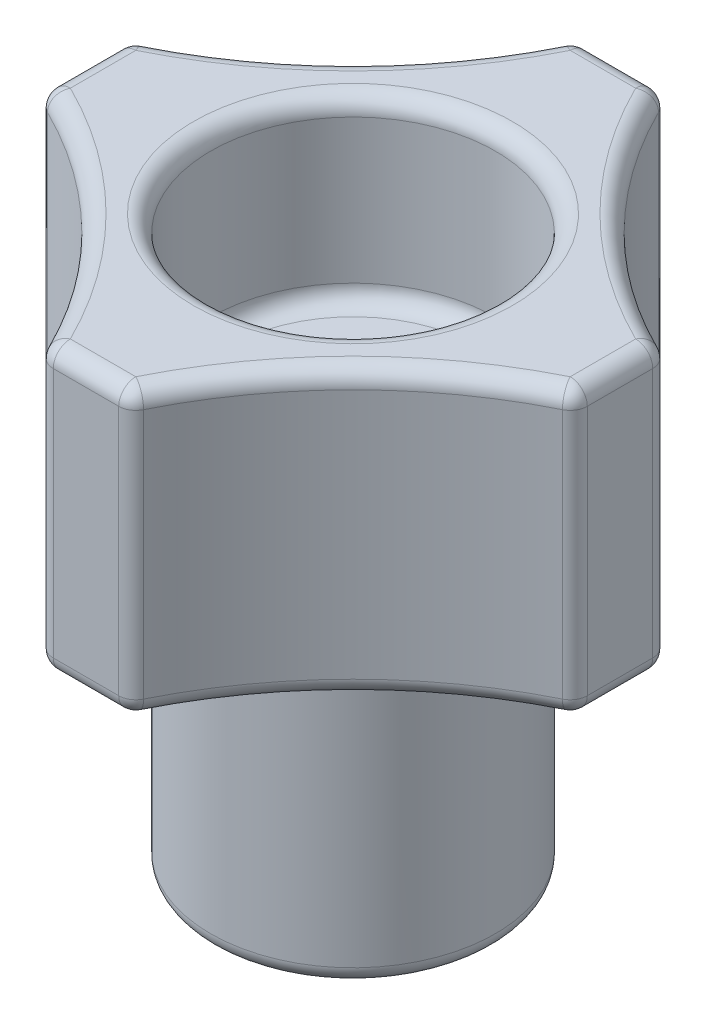
from build123d import *

# Parameters (mm, degrees)
SKETCH1_W           = 23.8125
SKETCH1_H           = 23.8125
BOSS_EXTRUDE1_DEPTH = 12.7
SKETCH3_R           = 20.6375
CUT_EXTRUDE1_DEPTH  = 22.090461781
CIRPATTERN1_COUNT   = 4
SKETCH4_R           = 6.35
BOSS_EXTRUDE2_DEPTH = 12.7
SKETCH5_R           = 3.175
CUT_EXTRUDE2_DEPTH  = 31.47421169
SKETCH6_R           = 6.35
CUT_EXTRUDE3_DEPTH  = 7.9375
FILLET1_R           = 0.762


with BuildPart() as part:
    # Sketch1 → Boss-Extrude1 (new body)
    with BuildSketch(Plane(origin=(0, 0, 0), x_dir=(1, 0, 0), z_dir=(0, 1, 0))):
        Rectangle(SKETCH1_W, SKETCH1_H)
    extrude(amount=BOSS_EXTRUDE1_DEPTH)

    # Sketch3 → Cut-Extrude1 (cut, through all)
    with BuildSketch(Plane(origin=(0, 12.7, 0), x_dir=(1, 0, 0), z_dir=(0, 1, 0))):
        with Locations((20.6375, 20.6375)):
            Circle(SKETCH3_R)
    cut_extrude1 = extrude(amount=-CUT_EXTRUDE1_DEPTH, mode=Mode.SUBTRACT)

    # CirPattern1: Cut-Extrude1 ×4 about axis
    cirpattern1_axis = Axis((0, 50, 0), (0, -1, 0))
    for i in range(1, CIRPATTERN1_COUNT):
        add(cut_extrude1.rotate(cirpattern1_axis, i * 360 / CIRPATTERN1_COUNT), mode=Mode.SUBTRACT)

    # Sketch4 → Boss-Extrude2 (add)
    with BuildSketch(Plane.XZ):
        Circle(SKETCH4_R)
    extrude(amount=BOSS_EXTRUDE2_DEPTH)

    # Sketch5 → Cut-Extrude2 (cut, through all)
    with BuildSketch(Plane(origin=(0, 12.7, 0), x_dir=(1, 0, 0), z_dir=(0, 1, 0))):
        Circle(SKETCH5_R)
    extrude(amount=-CUT_EXTRUDE2_DEPTH, mode=Mode.SUBTRACT)

    # Sketch6 → Cut-Extrude3 (cut)
    with BuildSketch(Plane(origin=(0, 12.7, 0), x_dir=(1, 0, 0), z_dir=(0, 1, 0))):
        Circle(SKETCH6_R)
    extrude(amount=-CUT_EXTRUDE3_DEPTH, mode=Mode.SUBTRACT)

    # Fillet1
    fillet1_edges = [part.edges().sort_by_distance(p)[0] for p in [
        (-6.35, 0, 0),
        (0, 12.7, 11.90625),
        (-11.90625, 12.7, 0),
        (0, 12.7, -11.90625),
        (11.90625, 12.7, 0),
        (0, 0, 11.90625),
        (-11.90625, 0, 0),
        (0, 0, -11.90625),
        (11.90625, 0, 0),
        (11.90625, 6.35, -1.937989854),
        (1.937989854, 6.35, -11.90625),
        (6.044583803, 0, -6.044583803),
        (6.044583803, 12.7, -6.044583803),
        (11.90625, 6.35, 1.937989854),
        (1.937989854, 6.35, 11.90625),
        (6.044583803, 0, 6.044583803),
        (6.044583803, 12.7, 6.044583803),
        (-11.90625, 6.35, 1.937989854),
        (-1.937989854, 6.35, 11.90625),
        (-6.044583803, 12.7, 6.044583803),
        (-6.044583803, 0, 6.044583803),
        (-1.937989854, 6.35, -11.90625),
        (-11.90625, 6.35, -1.937989854),
        (-6.044583803, 12.7, -6.044583803),
        (-6.044583803, 0, -6.044583803),
        (-6.35, -12.7, 0),
        (-3.175, -12.7, 0),
        (-3.175, 4.7625, 0),
        (-6.35, 4.7625, 0),
        (-6.35, 12.7, 0),
    ]]
    fillet(fillet1_edges, radius=FILLET1_R)


solid = part.part
